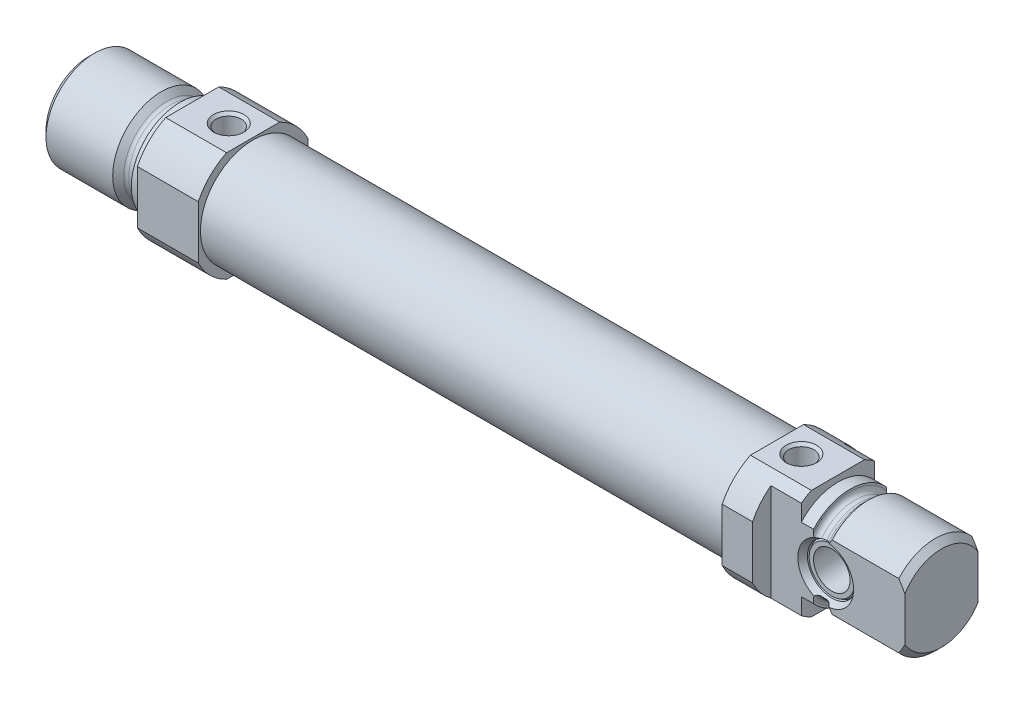
from build123d import *

# Parameters (mm, degrees)
BOSS_EXTRUDE1_DEPTH     = 10
SKETCH3_W               = 86
SKETCH3_H               = 8.65
SKETCH4_W               = 18
SKETCH4_H               = 18
BOSS_EXTRUDE2_DEPTH     = 10
SKETCH5_W               = 10
SKETCH5_H               = 10
CUT_EXTRUDE1_DEPTH      = 10
CUT_EXTRUDE1_DEPTH_BACK = 10
HOLE1_D                 = 4.134
HOLE1_DEPTH             = 9
HOLE1_CSINK_D           = 5
HOLE1_CSINK_ANGLE       = 90
HOLE2_D                 = 4.134
HOLE2_DEPTH             = 11
HOLE2_CSINK_D           = 5
HOLE2_CSINK_ANGLE       = 90
HOLE2_TIP               = 1.193383006


with BuildPart() as part:
    # Sketch1 → Revolve1 (revolve)
    with BuildSketch(Plane.XY):
        with BuildLine():
            Line((0, 0), (0, 7))
            Line((0, 7), (1, 8))
            Line((1, 8), (11.95, 8))
            Line((11.95, 8), (12.865685425, 7.084314575))
            ThreePointArc((12.865685425, 7.084314575), (13.125224104, 6.910896374), (13.43137085, 6.85))
            Line((13.43137085, 6.85), (14.2, 6.85))
            ThreePointArc((14.2, 6.85), (14.765685425, 7.084314575), (15, 7.65))
            Line((15, 7.65), (15, 8))
            Line((15, 8), (17, 8))
            Line((17, 8), (17, 0))
            Line((17, 0), (0, 0))
        make_face()
    revolve(axis=Axis((17, 0, 0), (-1, 0, 0)))

    # Sketch2 → Boss-Extrude1 (add)
    with BuildSketch(Plane(origin=(17, 0, 0), x_dir=(0, 0, -1), z_dir=(1, 0, 0))):
        with BuildLine():
            Line((-4.358898944, -9), (4.358898944, -9))
            ThreePointArc((4.358898944, -9), (7.071067812, -7.071067812), (9, -4.358898944))
            Line((9, -4.358898944), (9, 4.358898944))
            ThreePointArc((9, 4.358898944), (7.071067812, 7.071067812), (4.358898944, 9))
            Line((4.358898944, 9), (-4.358898944, 9))
            ThreePointArc((-4.358898944, 9), (-7.071067812, 7.071067812), (-9, 4.358898944))
            Line((-9, 4.358898944), (-9, -4.358898944))
            ThreePointArc((-9, -4.358898944), (-7.071067812, -7.071067812), (-4.358898944, -9))
        make_face()
    extrude(amount=BOSS_EXTRUDE1_DEPTH)

    # Sketch3 → Revolve2 (revolve)
    with BuildSketch(Plane.XY):
        with Locations((70, 4.325)):
            Rectangle(SKETCH3_W, SKETCH3_H)
    revolve(axis=Axis((113, 0, 0), (-1, 0, 0)))

    # Sketch4 → Boss-Extrude2 (add)
    with BuildSketch(Plane(origin=(113, 0, 0), x_dir=(0, 0, -1), z_dir=(1, 0, 0))):
        Rectangle(SKETCH4_W, SKETCH4_H)
    extrude(amount=BOSS_EXTRUDE2_DEPTH)

    # Sketch5 → Cut-Revolve1 (revolve, cut)
    with BuildSketch(Plane.XY):
        with Locations((118, 15)):
            Rectangle(SKETCH5_W, SKETCH5_H)
    revolve(axis=Axis((123, 0, 0), (-1, 0, 0)), mode=Mode.SUBTRACT)

    # Sketch6 → Revolve3 (revolve)
    with BuildSketch(Plane.XY):
        with BuildLine():
            Line((123, 0), (123, 8))
            Line((123, 8), (125, 8))
            Line((125, 8), (125, 7.65))
            ThreePointArc((125, 7.65), (125.234314575, 7.084314575), (125.8, 6.85))
            Line((125.8, 6.85), (126.56862915, 6.85))
            ThreePointArc((126.56862915, 6.85), (126.874775896, 6.910896374), (127.134314575, 7.084314575))
            Line((127.134314575, 7.084314575), (128.05, 8))
            Line((128.05, 8), (139, 8))
            Line((139, 8), (140, 7))
            Line((140, 7), (140, 0))
            Line((140, 0), (123, 0))
        make_face()
    revolve(axis=Axis((140, 0, 0), (-1, 0, 0)))

    # Sketch7 → Cut-Extrude1 (cut, two sides: drawn at the far end of the back side and taken through both)
    with BuildSketch(Plane(origin=(0, 0, 0), x_dir=(1, 0, 0), z_dir=(0, 1, 0)).offset(-CUT_EXTRUDE1_DEPTH_BACK)):
        Polygon((118, 18), (118, 6), (140, 6), (140, -6), (118, -6), (118, -18), (152, -18), (152, 18), align=None)
    extrude(amount=CUT_EXTRUDE1_DEPTH + CUT_EXTRUDE1_DEPTH_BACK, mode=Mode.SUBTRACT)

    # Sketch8 → Cut-Revolve2 (revolve, cut)
    with BuildSketch(Plane(origin=(127, 0, 0), x_dir=(0, 0, -1), z_dir=(1, 0, 0))):
        Polygon((-6.2, 0), (-6.2, 4.692820323), (-5, 4), (-4.5, 4), (-5, 3.711324865), (-5, 3), (5, 3), (5, 3.711324865), (4.5, 4), (5, 4), (6.2, 4.692820323), (6.2, 0), align=None)
    revolve(axis=Axis((127, 0, -5), (0, 0, 1)), mode=Mode.SUBTRACT)

    # Hole1
    with Locations(Plane(origin=(0, 9, 0), x_dir=(1, 0, 0), z_dir=(0, 1, 0))):
        with Locations((23, 0)):
            CounterSinkHole(HOLE1_D / 2, HOLE1_CSINK_D / 2, depth=HOLE1_DEPTH, counter_sink_angle=HOLE1_CSINK_ANGLE)

    # Hole2
    with Locations(Plane(origin=(0, 9, 0), x_dir=(1, 0, 0), z_dir=(0, 1, 0))):
        with Locations((117, 0)):
            CounterSinkHole(HOLE2_D / 2, HOLE2_CSINK_D / 2, depth=HOLE2_DEPTH, counter_sink_angle=HOLE2_CSINK_ANGLE)
            with Locations((0, 0, -(HOLE2_DEPTH + HOLE2_TIP / 2))):  # 120° drill point
                Cone(0, HOLE2_D / 2, HOLE2_TIP, mode=Mode.SUBTRACT)

    # Sketch13 → Cut-Revolve3 (revolve, cut)
    with BuildSketch(Plane.XY):
        Polygon((-5, 0), (-5, 3), (41.2, 3), (41.2, 8), (95.2, 8), (95.2, 0), align=None)
    revolve(axis=Axis((95.2, 0, 0), (-1, 0, 0)), mode=Mode.SUBTRACT)


solid = part.part
